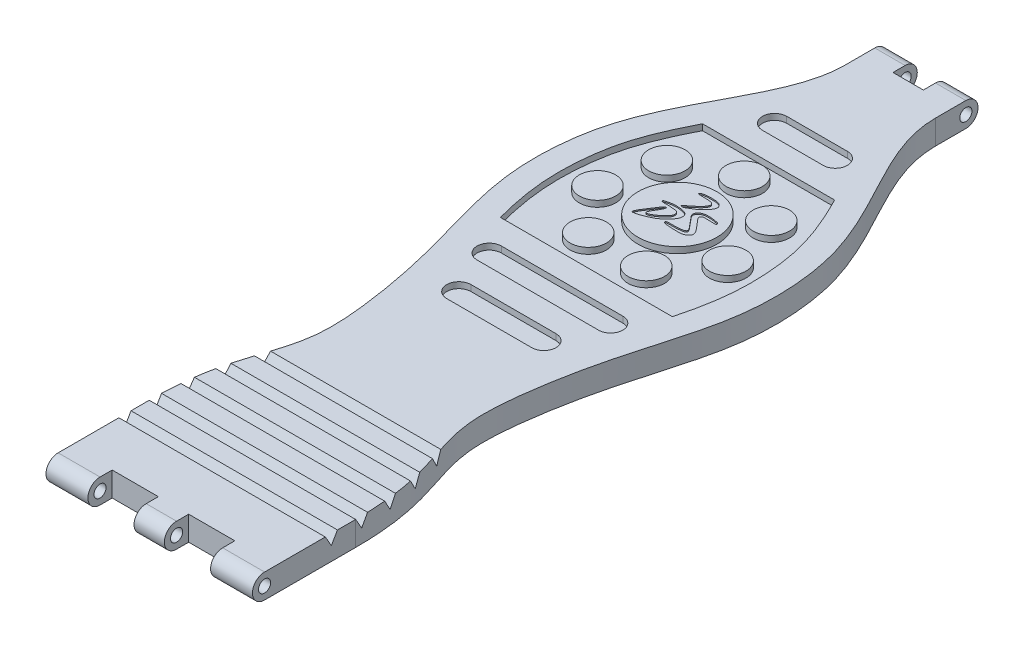
from build123d import *

# Parameters (mm, degrees)
SKETCH1_W           = 43.18
SKETCH1_H           = 19.05
SKETCH1_W_2         = 19.05
SKETCH1_H_2         = 6.35
BOSS_EXTRUDE1_DEPTH = 5.08
SKETCH2_R           = 2.54
BOSS_EXTRUDE2_DEPTH = 43.18
SKETCH3_R           = 2.54
BOSS_EXTRUDE3_DEPTH = 19.05
SKETCH4_R           = 1.27
CUT_EXTRUDE1_DEPTH  = 19.05
SKETCH5_R           = 1.27
CUT_EXTRUDE2_DEPTH  = 43.18
SKETCH6_W           = 9.652
SKETCH6_H           = 5.08
SKETCH6_W_2         = 6.35
SKETCH6_H_2         = 10.16
CUT_EXTRUDE3_DEPTH  = 5.08
CUT_EXTRUDE4_DEPTH  = 164.322880864
LPATTERN1_COUNT     = 5
LPATTERN1_PITCH     = 6.35
CUT_EXTRUDE5_DEPTH  = 1.27
SKETCH10_R          = 3.81
BOSS_EXTRUDE4_DEPTH = 1.27
CIRPATTERN1_COUNT   = 7
SKETCH11_R          = 8.255
BOSS_EXTRUDE5_DEPTH = 1.27
CUT_EXTRUDE6_DEPTH  = 0.254
SCALE1_SCALE        = 1.5


with BuildPart() as part:
    # Sketch1 → Boss-Extrude1 (new body)
    with BuildSketch(Plane(origin=(0, 0, 0), x_dir=(1, 0, 0), z_dir=(0, 1, 0))):
        with BuildLine():
            add(Edge.make_bspline(
                [(9.525, 152.4), (9.525, 140.780535582), (22.949484723, 127.280133905), (26.907137569, 91.716643985), (18.605209668, 80.048291144), (14.416649155, 41.533903748), (21.59, 36.241984912), (21.59, 19.05)],
                knots=[0, 0, 0, 0, 0.318102217, 0.396519921, 0.741104029, 0.805759338, 1, 1, 1, 1], degree=3))
            Line((21.59, 19.05), (-21.59, 19.05))
            add(Edge.make_bspline(
                [(-9.525, 152.4), (-9.525, 140.780535582), (-22.949484723, 127.280133905), (-26.907137569, 91.716643985), (-18.605209668, 80.048291144), (-14.416649155, 41.533903748), (-21.59, 36.241984912), (-21.59, 19.05)],
                knots=[0, 0, 0, 0, 0.318102217, 0.396519921, 0.741104029, 0.805759338, 1, 1, 1, 1], degree=3))
            Line((-9.525, 152.4), (9.525, 152.4))
        make_face()
        with Locations((0, 9.525)):
            Rectangle(SKETCH1_W, SKETCH1_H)
        with Locations((0, 155.575)):
            Rectangle(SKETCH1_W_2, SKETCH1_H_2)
    extrude(amount=-BOSS_EXTRUDE1_DEPTH)

    # Sketch2 → Boss-Extrude2 (add)
    with BuildSketch(Plane.ZY.offset(21.59)):
        with Locations((0, -2.54)):
            Circle(SKETCH2_R)
    extrude(amount=-BOSS_EXTRUDE2_DEPTH)

    # Sketch3 → Boss-Extrude3 (add)
    with BuildSketch(Plane.ZY.offset(9.525)):
        with Locations((-158.75, -2.54)):
            Circle(SKETCH3_R)
    extrude(amount=-BOSS_EXTRUDE3_DEPTH)

    # Sketch4 → Cut-Extrude1 (cut)
    with BuildSketch(Plane.ZY.offset(9.525)):
        with Locations((-158.75, -2.54)):
            Circle(SKETCH4_R)
    extrude(amount=-CUT_EXTRUDE1_DEPTH, mode=Mode.SUBTRACT)

    # Sketch5 → Cut-Extrude2 (cut)
    with BuildSketch(Plane.ZY.offset(21.59)):
        with Locations((0, -2.54)):
            Circle(SKETCH5_R)
    extrude(amount=-CUT_EXTRUDE2_DEPTH, mode=Mode.SUBTRACT)

    # Sketch6 → Cut-Extrude3 (cut)
    with BuildSketch(Plane(origin=(0, 0, 0), x_dir=(1, 0, 0), z_dir=(0, 1, 0))):
        with Locations((-8.001, 0)):
            Rectangle(SKETCH6_W, SKETCH6_H)
        with Locations((8.001, 0)):
            Rectangle(SKETCH6_W, SKETCH6_H)
        with Locations((0, 161.29)):
            Rectangle(SKETCH6_W_2, SKETCH6_H_2)
    extrude(amount=-CUT_EXTRUDE3_DEPTH, mode=Mode.SUBTRACT)

    # Sketch7 → Cut-Extrude4 (cut, symmetric)
    with BuildSketch(Plane(origin=(0, 0, 0), x_dir=(0, 0, -1), z_dir=(1, 0, 0))):
        Polygon((15.24, 0), (13.97, -2.199704526), (12.7, 0), align=None)
    cut_extrude4 = extrude(amount=CUT_EXTRUDE4_DEPTH, both=True, mode=Mode.SUBTRACT)

    # LPattern1: Cut-Extrude4 ×5
    with Locations(*[(0, 0, -i * LPATTERN1_PITCH) for i in range(1, LPATTERN1_COUNT)]):
        add(cut_extrude4, mode=Mode.SUBTRACT)

    # Sketch8 → Cut-Extrude5 (cut)
    with BuildSketch(Plane(origin=(0, 0, 0), x_dir=(1, 0, 0), z_dir=(0, 1, 0))):
        with BuildLine():
            Line((13.816973205, 127), (-13.816973205, 127))
            add(Edge.make_bspline(
                [(-13.816973205, 127), (-14.024160271, 126.594495335), (-14.229109287, 126.188796233), (-15.46672248, 123.701706277), (-16.42651403, 121.611393468), (-17.639873613, 118.434068597), (-18.006811659, 117.368027547), (-18.649379348, 115.216034408), (-18.922141257, 114.135908442), (-19.610034821, 110.781684376), (-19.892580774, 108.428848367), (-20.051290747, 105.635057518), (-20.073450168, 105.083621268), (-20.099730896, 104.003053034), (-20.103857287, 103.473811172), (-20.091018532, 101.914572905), (-20.048893344, 100.913084541), (-19.834509314, 97.984136547), (-19.574744191, 96.131276679), (-18.88713266, 92.509868135), (-18.46642666, 90.740852109), (-17.983013999, 88.9)],
                knots=[0.237803755, 0.237803755, 0.237803755, 0.237803755, 0.25, 0.25, 0.3125, 0.3125, 0.34375, 0.34375, 0.375, 0.375, 0.4375, 0.4375, 0.453125, 0.453125, 0.46875, 0.46875, 0.5, 0.5, 0.5625, 0.5625, 0.62215026, 0.62215026, 0.62215026, 0.62215026], degree=3))
            Line((-17.983013999, 88.9), (17.983013999, 88.9))
            add(Edge.make_bspline(
                [(13.816973205, 127), (14.024160271, 126.594495335), (14.229109287, 126.188796233), (15.46672248, 123.701706277), (16.42651403, 121.611393468), (17.639873613, 118.434068597), (18.006811659, 117.368027547), (18.649379348, 115.216034408), (18.922141257, 114.135908442), (19.610034821, 110.781684376), (19.892580774, 108.428848367), (20.051290747, 105.635057518), (20.073450168, 105.083621268), (20.099730896, 104.003053034), (20.103857287, 103.473811172), (20.091018532, 101.914572905), (20.048893344, 100.913084541), (19.834509314, 97.984136547), (19.574744191, 96.131276679), (18.88713266, 92.509868135), (18.46642666, 90.740852109), (17.983013999, 88.9)],
                knots=[0.237803755, 0.237803755, 0.237803755, 0.237803755, 0.25, 0.25, 0.3125, 0.3125, 0.34375, 0.34375, 0.375, 0.375, 0.4375, 0.4375, 0.453125, 0.453125, 0.46875, 0.46875, 0.5, 0.5, 0.5625, 0.5625, 0.62215026, 0.62215026, 0.62215026, 0.62215026], degree=3))
        make_face()
        with BuildLine():
            Line((-12.7, 83.82), (12.7, 83.82))
            ThreePointArc((12.7, 83.82), (15.24, 81.28), (12.7, 78.74))
            Line((12.7, 78.74), (-12.7, 78.74))
            ThreePointArc((-12.7, 78.74), (-15.24, 81.28), (-12.7, 83.82))
        make_face()
        with BuildLine():
            Line((-8.89, 73.66), (8.89, 73.66))
            ThreePointArc((8.89, 73.66), (11.43, 71.12), (8.89, 68.58))
            Line((8.89, 68.58), (-8.89, 68.58))
            ThreePointArc((-8.89, 68.58), (-11.43, 71.12), (-8.89, 73.66))
        make_face()
        with BuildLine():
            Line((-6.35, 137.16), (6.35, 137.16))
            ThreePointArc((6.35, 137.16), (8.89, 134.62), (6.35, 132.08))
            Line((6.35, 132.08), (-6.35, 132.08))
            ThreePointArc((-6.35, 132.08), (-8.89, 134.62), (-6.35, 137.16))
        make_face()
    extrude(amount=-CUT_EXTRUDE5_DEPTH, mode=Mode.SUBTRACT)

    # Sketch10 → Boss-Extrude4 (add)
    with BuildSketch(Plane(origin=(0, -1.27, 0), x_dir=(1, 0, 0), z_dir=(0, 1, 0))):
        with Locations(Location((0, 121.92, 0), (0, 0, 90))):
            Circle(SKETCH10_R)
    boss_extrude4 = extrude(amount=BOSS_EXTRUDE4_DEPTH)

    # CirPattern1: Boss-Extrude4 ×7 about axis
    cirpattern1_axis = Axis((0, 0, -107.95), (0, 1, 0))
    for i in range(1, CIRPATTERN1_COUNT):
        add(boss_extrude4.rotate(cirpattern1_axis, i * 360 / CIRPATTERN1_COUNT))

    # Sketch11 → Boss-Extrude5 (add)
    with BuildSketch(Plane(origin=(0, -1.27, 0), x_dir=(1, 0, 0), z_dir=(0, 1, 0))):
        with Locations(Location((0, 107.95, 0), (0, 0, 90))):
            Circle(SKETCH11_R)
    extrude(amount=BOSS_EXTRUDE5_DEPTH)

    # Sketch13 → Cut-Extrude6 (cut)
    with BuildSketch(Plane(origin=(0, 0, 0), x_dir=(1, 0, 0), z_dir=(0, 1, 0))):
        with BuildLine():
            add(Edge.make_bspline(
                [(5.897916854, 110.374483497), (5.879187482, 110.4501446), (5.777394009, 110.646745493), (5.188455601, 110.729283622), (4.502389781, 110.882397824), (3.597795928, 110.903713118), (2.744430864, 110.873821827), (2.016168331, 110.547684695), (1.609116407, 110.092321615), (1.448727506, 109.411908851), (2.099455981, 108.645356854), (2.773218096, 107.758299503), (3.481272123, 107.026810629), (3.865996646, 106.485675888), (4.023345843, 106.121312384), (3.868898805, 105.880806655), (3.518772903, 105.701901606), (2.831387864, 105.624790009), (1.894522101, 105.532222672), (1.018059574, 105.557016449), (0.405410773, 105.555321994), (0.107513465, 105.478027776), (-0.07481012, 105.231118783), (0.416948991, 104.967138467), (0.980574245, 104.933942931), (1.87171849, 104.839790338), (2.870996644, 104.864224892), (3.847214204, 104.789866598), (4.614441377, 105.09336895), (5.046659155, 105.434670026), (5.236124678, 105.790785852), (5.289390853, 106.18213582), (5.096785867, 106.636494269), (4.802599413, 107.086211474), (4.454763204, 107.43887774), (4.209439034, 107.782145272), (3.932165127, 108.104324059), (3.567432407, 108.497560915), (3.230600218, 108.922553642), (2.907120104, 109.309851083), (2.701517179, 109.688210177), (2.932756199, 110.078110155), (3.429456932, 110.212686482), (4.166375068, 110.126204445), (4.944708612, 110.181294158), (5.543601257, 110.134900885), (5.811532247, 110.1708132), (5.917068866, 110.260889855), (5.907527496, 110.335659354), (5.897916854, 110.374483497)],
                knots=[0, 0, 0, 0, 0.007967842, 0.02284063, 0.058736288, 0.087669789, 0.120199417, 0.151122045, 0.171586137, 0.184516981, 0.223592952, 0.268529554, 0.310884813, 0.331499754, 0.343293116, 0.349379584, 0.360542988, 0.384925918, 0.423995443, 0.463129648, 0.480211202, 0.490538339, 0.495987628, 0.508440394, 0.53378025, 0.565950392, 0.602255468, 0.644043474, 0.67007611, 0.690282045, 0.702523421, 0.713089149, 0.732150924, 0.754233619, 0.771685313, 0.78576727, 0.800094227, 0.817887662, 0.844235299, 0.858518301, 0.874127531, 0.886177613, 0.901951969, 0.927093343, 0.966949282, 0.986324173, 0.992486705, 0.995911445, 1, 1, 1, 1], degree=3))
        make_face()
        with BuildLine():
            Line((-4.763928267, 104.991279685), (-2.976237449, 107.720656378))
            add(Edge.make_bspline(
                [(-2.976237449, 107.720656378), (-2.908865573, 107.827060807), (-2.782247565, 107.948317777), (-2.603638033, 108.070211378), (-2.462709085, 108.099147537), (-2.311594824, 107.976307891), (-2.390479438, 107.656584532), (-2.624558871, 107.155275578), (-3.060106283, 106.436277924), (-3.474900363, 105.771335869), (-3.668495395, 105.306121616), (-3.708270984, 104.879981383), (-3.024636502, 105.022387777), (-2.531690655, 105.326412963), (-1.815636597, 105.771790877), (-1.21111745, 106.330372195), (-0.692864373, 106.857974058), (-0.331050747, 107.325908279), (-0.291780935, 107.788086748), (-0.426445296, 108.464858851), (-1.483856375, 108.580319565), (-2.415733289, 108.659076412), (-3.207066955, 108.666245017), (-3.679936079, 108.641764853), (-3.96437943, 108.666652057), (-4.036166415, 108.789777865), (-4.038059747, 108.867982534)],
                knots=[0, 0, 0, 0, 0.028901141, 0.040121591, 0.050249778, 0.059683396, 0.079637302, 0.116475698, 0.19384387, 0.272446579, 0.293654293, 0.317291688, 0.348337881, 0.411714141, 0.47091266, 0.537541329, 0.602807893, 0.64443744, 0.668799284, 0.709518186, 0.788260885, 0.872674677, 0.941240214, 0.966274798, 0.986326544, 1, 1, 1, 1], degree=3))
            add(Edge.make_bspline(
                [(-4.038059747, 108.867982534), (-4.040875344, 108.984281632), (-3.359983122, 109.190278291), (-2.661485355, 109.34299437), (-1.463525101, 109.462722693), (-0.339091981, 109.289421908), (0.841371224, 108.93931513), (1.047290716, 107.810164328), (0.624774988, 106.960671283), (-0.101026571, 106.248893495), (-0.927911787, 105.330463456), (-2.137869608, 104.614225512), (-3.351784015, 104.122552655), (-4.289528982, 103.77958949), (-4.864935748, 103.693359063), (-5.236393246, 103.624064493), (-5.357809522, 103.88050519), (-5.081396813, 104.379402522), (-5.102306246, 104.47465737), (-4.763928267, 104.991279685)],
                knots=[0, 0, 0, 0, 0.035650605, 0.092587223, 0.17108072, 0.257806916, 0.326934612, 0.389171432, 0.454193191, 0.508585236, 0.58950913, 0.697497475, 0.781320619, 0.850811356, 0.889001106, 0.904315577, 0.914582951, 0.937148655, 1, 1, 1, 1], degree=3))
        make_face()
        with BuildLine():
            add(Edge.make_bspline(
                [(-1.511797846, 114.021857951), (-1.442062153, 114.168494445), (-0.945489663, 114.385784708), (-0.013521237, 114.489125343), (1.05584344, 114.48909321), (2.047655648, 114.393202363), (2.705625722, 114.072179342), (3.099406286, 113.378345628), (2.738294181, 112.490547931), (2.04702961, 111.669107228), (1.256705659, 110.933023514), (0.430560963, 110.455722181), (-0.213473858, 110.053887553), (-0.757053383, 109.800922942), (-1.092804802, 109.822927728), (-1.182711429, 109.89913645)],
                knots=[0, 0, 0, 0, 0.042326132, 0.137240054, 0.264506229, 0.335187826, 0.412965306, 0.455949246, 0.542825385, 0.649198114, 0.759646438, 0.837282226, 0.912449506, 0.970561481, 1, 1, 1, 1], degree=3))
            add(Edge.make_bspline(
                [(-1.511797846, 114.021857951), (-1.529547862, 113.984534163), (-1.557273163, 113.824043762), (-1.028767944, 113.840711604), (-0.539918107, 113.781648206), (0.221265047, 113.827069333), (0.935052281, 113.738124384), (1.533629702, 113.632030921), (1.879818418, 113.164674103), (1.564232137, 112.498815919), (1.100557335, 111.953629909), (0.453292594, 111.349457863), (-0.166070843, 110.863346726), (-0.741110251, 110.385020651), (-1.091556301, 110.17119157), (-1.224577714, 109.976448096), (-1.218008336, 109.929055626), (-1.182711429, 109.89913645)],
                knots=[0, 0, 0, 0, 0.011373414, 0.060873653, 0.126758706, 0.224901148, 0.323555525, 0.397977387, 0.434797696, 0.518923712, 0.628480134, 0.708164305, 0.839679307, 0.917539764, 0.981654804, 0.988925241, 1, 1, 1, 1], degree=3))
        make_face()
    extrude(amount=-CUT_EXTRUDE6_DEPTH, mode=Mode.SUBTRACT)


with BuildPart() as part_1:
    # Scale1: scaled about (-0.000394663, -2.680495505, -75.213781211)
    add(part.part.scale(SCALE1_SCALE).moved(Location((0.000197332, 1.340247753, 37.606890605))))


solid = part_1.part
